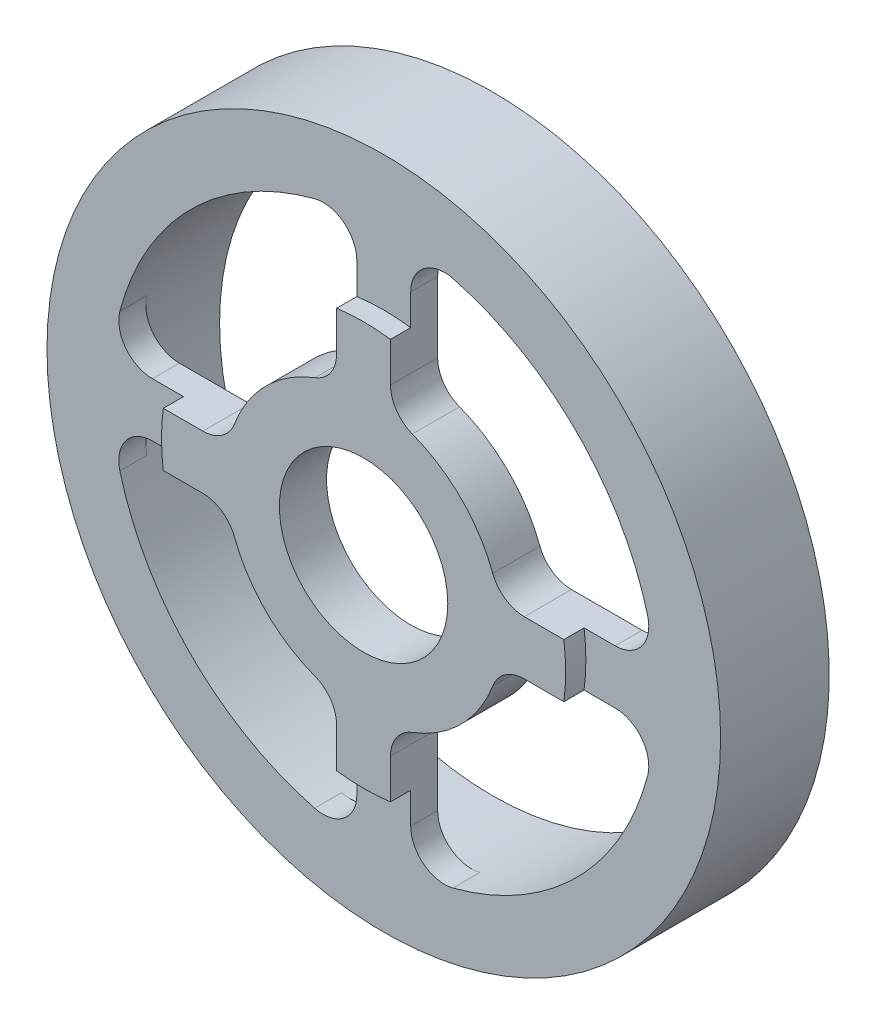
from build123d import *

# Parameters (mm, degrees)
ESQUISSE1_R             = 50
ESQUISSE1_R_2           = 12.5
BOSS_EXTRU_1_DEPTH      = 4
ESQUISSE2_R             = 30
ESQUISSE2_R_2           = 12.5
BOSS_EXTRU_2_DEPTH      = 3
ENL_V_MAT_EXTRU_1_DEPTH = 23
ESQUISSE5_R             = 50
ESQUISSE5_R_2           = 40.5
BOSS_EXTRU_3_DEPTH      = 12.125


with BuildPart() as part:
    # Esquisse1 → Boss.-Extru.1 (new body)
    with BuildSketch(Plane.XY):
        Circle(ESQUISSE1_R)
        Circle(ESQUISSE1_R_2, mode=Mode.SUBTRACT)
    extrude(amount=BOSS_EXTRU_1_DEPTH)

    # Esquisse2 → Boss.-Extru.2 (add)
    with BuildSketch(Plane.XY.offset(4)):
        Circle(ESQUISSE2_R)
        Circle(ESQUISSE2_R_2, mode=Mode.SUBTRACT)
    extrude(amount=BOSS_EXTRU_2_DEPTH)

    # Esquisse4 → Enlèv. mat.-Extru.1 (cut)
    with BuildSketch(Plane(origin=(0, 0, 0), x_dir=(-1, 0, 0), z_dir=(0, 0, -1))):
        with BuildLine():
            Line((-4, 23.858960581), (-4, 34.340209667))
            ThreePointArc((-4, 34.340209667), (-5.945333747, 38.298620218), (-10.267605634, 39.176858916))
            ThreePointArc((-10.267605634, 39.176858916), (-28.637824638, 28.637824638), (-39.176858916, 10.267605634))
            ThreePointArc((-39.176858916, 10.267605634), (-38.298620218, 5.945333747), (-34.340209667, 4))
            Line((-34.340209667, 4), (-23.858960581, 4))
            ThreePointArc((-23.858960581, 4), (-21.014978286, 4.887608396), (-19.180733016, 7.235294118))
            ThreePointArc((-19.180733016, 7.235294118), (-14.495689014, 14.495689014), (-7.235294118, 19.180733016))
            ThreePointArc((-7.235294118, 19.180733016), (-4.887608396, 21.014978286), (-4, 23.858960581))
        make_face()
        with BuildLine():
            Line((4, 23.858960581), (4, 34.340209667))
            ThreePointArc((4, 34.340209667), (5.945333747, 38.298620218), (10.267605634, 39.176858916))
            ThreePointArc((10.267605634, 39.176858916), (28.637824638, 28.637824638), (39.176858916, 10.267605634))
            ThreePointArc((39.176858916, 10.267605634), (38.298620218, 5.945333747), (34.340209667, 4))
            Line((34.340209667, 4), (23.858960581, 4))
            ThreePointArc((23.858960581, 4), (21.014978286, 4.887608396), (19.180733016, 7.235294118))
            ThreePointArc((19.180733016, 7.235294118), (14.495689014, 14.495689014), (7.235294118, 19.180733016))
            ThreePointArc((7.235294118, 19.180733016), (4.887608396, 21.014978286), (4, 23.858960581))
        make_face()
        with BuildLine():
            Line((-23.858960581, -4), (-34.340209667, -4))
            ThreePointArc((-34.340209667, -4), (-38.298620218, -5.945333747), (-39.176858916, -10.267605634))
            ThreePointArc((-39.176858916, -10.267605634), (-28.637824638, -28.637824638), (-10.267605634, -39.176858916))
            ThreePointArc((-10.267605634, -39.176858916), (-5.945333747, -38.298620218), (-4, -34.340209667))
            Line((-4, -34.340209667), (-4, -23.858960581))
            ThreePointArc((-4, -23.858960581), (-4.887608396, -21.014978286), (-7.235294118, -19.180733016))
            ThreePointArc((-7.235294118, -19.180733016), (-14.495689014, -14.495689014), (-19.180733016, -7.235294118))
            ThreePointArc((-19.180733016, -7.235294118), (-21.014978286, -4.887608396), (-23.858960581, -4))
        make_face()
        with BuildLine():
            Line((23.858960581, -4), (34.340209667, -4))
            ThreePointArc((34.340209667, -4), (38.298620218, -5.945333747), (39.176858916, -10.267605634))
            ThreePointArc((39.176858916, -10.267605634), (28.637824638, -28.637824638), (10.267605634, -39.176858916))
            ThreePointArc((10.267605634, -39.176858916), (5.945333747, -38.298620218), (4, -34.340209667))
            Line((4, -34.340209667), (4, -23.858960581))
            ThreePointArc((4, -23.858960581), (4.887608396, -21.014978286), (7.235294118, -19.180733016))
            ThreePointArc((7.235294118, -19.180733016), (14.495689014, -14.495689014), (19.180733016, -7.235294118))
            ThreePointArc((19.180733016, -7.235294118), (21.014978286, -4.887608396), (23.858960581, -4))
        make_face()
    extrude(amount=-ENL_V_MAT_EXTRU_1_DEPTH, mode=Mode.SUBTRACT)

    # Esquisse5 → Boss.-Extru.3 (add)
    with BuildSketch(Plane(origin=(0, 0, 0), x_dir=(-1, 0, 0), z_dir=(0, 0, -1))):
        Circle(ESQUISSE5_R)
        Circle(ESQUISSE5_R_2, mode=Mode.SUBTRACT)
    extrude(amount=BOSS_EXTRU_3_DEPTH)


solid = part.part
